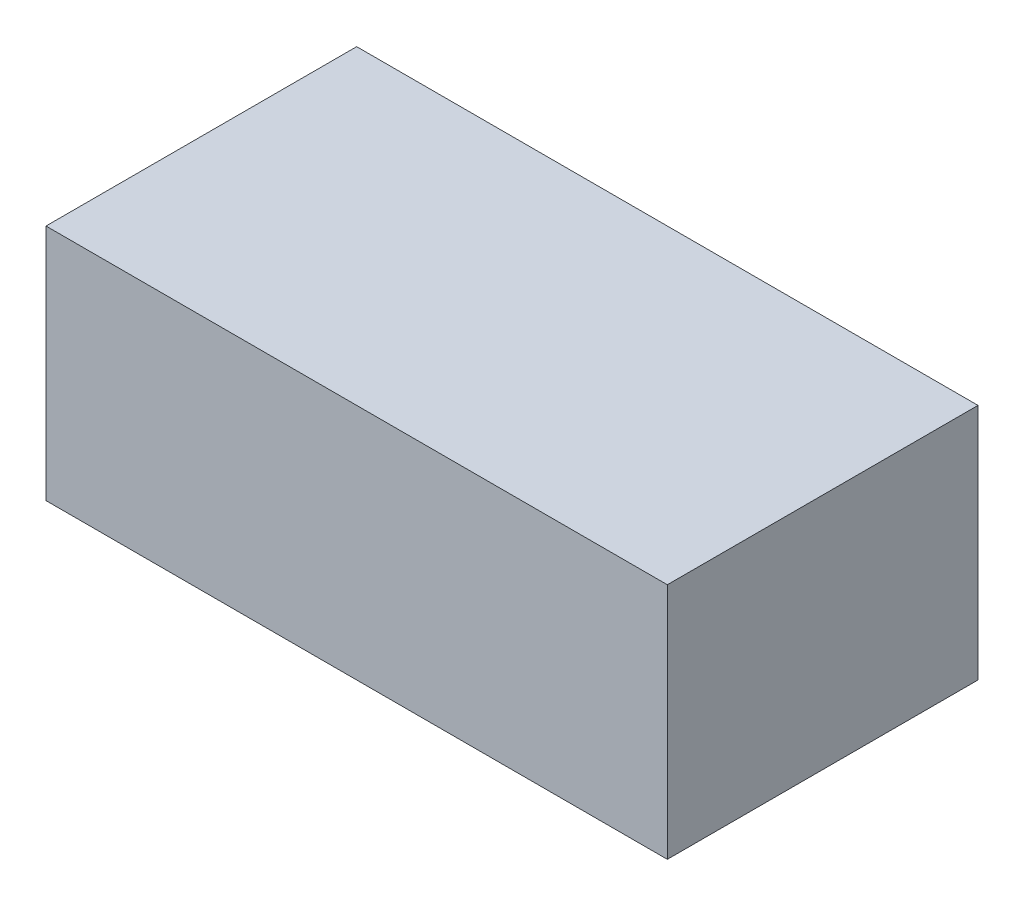
from build123d import *

# Parameters (mm, degrees)
SKETCH2_W           = 290
SKETCH2_H           = 145
BOSS_EXTRUDE1_DEPTH = 111


with BuildPart() as part:
    # Sketch2 → Boss-Extrude1 (new body)
    with BuildSketch(Plane(origin=(0, 0, 0), x_dir=(1, 0, 0), z_dir=(0, 1, 0))):
        Rectangle(SKETCH2_W, SKETCH2_H)
    extrude(amount=BOSS_EXTRUDE1_DEPTH)


solid = part.part
